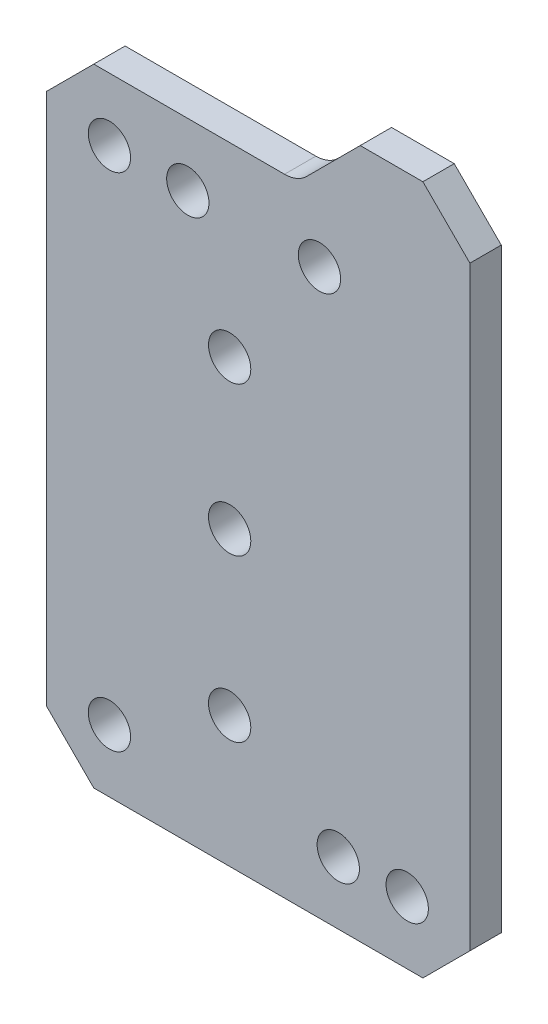
from build123d import *

# Parameters (mm, degrees)
SKETCH_1_R      = 6.75
EXTRUDE_1_DEPTH = 10


with BuildPart() as part:
    # Эскиз1 → Бобышка-Вытянуть1 (new body)
    with BuildSketch(Plane.XY):
        with BuildLine():
            Line((469.898536303, 620), (469.898536303, 450))
            Line((469.898536303, 450), (484.898536303, 435))
            Line((484.898536303, 435), (589.898536303, 435))
            Line((589.898536303, 435), (604.898536303, 450))
            Line((604.898536303, 450), (604.898536303, 640))
            Line((604.898536303, 640), (589.898536303, 655))
            Line((589.898536303, 655), (569.898536303, 655))
            Line((569.898536303, 655), (552.827468491, 637.928932188))
            ThreePointArc((552.827468491, 637.928932188), (549.583235002, 635.761204675), (545.756400679, 635))
            Line((545.756400679, 635), (484.898536303, 635))
            Line((484.898536303, 635), (469.898536303, 620))
        make_face()
        with Locations((584.898536303, 455)):
            Circle(SKETCH_1_R, mode=Mode.SUBTRACT)
        with Locations((562.898536303, 455)):
            Circle(SKETCH_1_R, mode=Mode.SUBTRACT)
        with Locations((489.898536303, 455)):
            Circle(SKETCH_1_R, mode=Mode.SUBTRACT)
        with Locations((528.246102145, 476.749727554)):
            Circle(SKETCH_1_R, mode=Mode.SUBTRACT)
        with Locations((528.246102144, 528.249727554)):
            Circle(SKETCH_1_R, mode=Mode.SUBTRACT)
        with Locations((528.246102143, 575.749727554)):
            Circle(SKETCH_1_R, mode=Mode.SUBTRACT)
        with Locations((514.898536303, 615)):
            Circle(SKETCH_1_R, mode=Mode.SUBTRACT)
        with Locations((489.898536303, 615)):
            Circle(SKETCH_1_R, mode=Mode.SUBTRACT)
        with Locations((556.898536303, 615)):
            Circle(SKETCH_1_R, mode=Mode.SUBTRACT)
    extrude(amount=EXTRUDE_1_DEPTH)


solid = part.part
